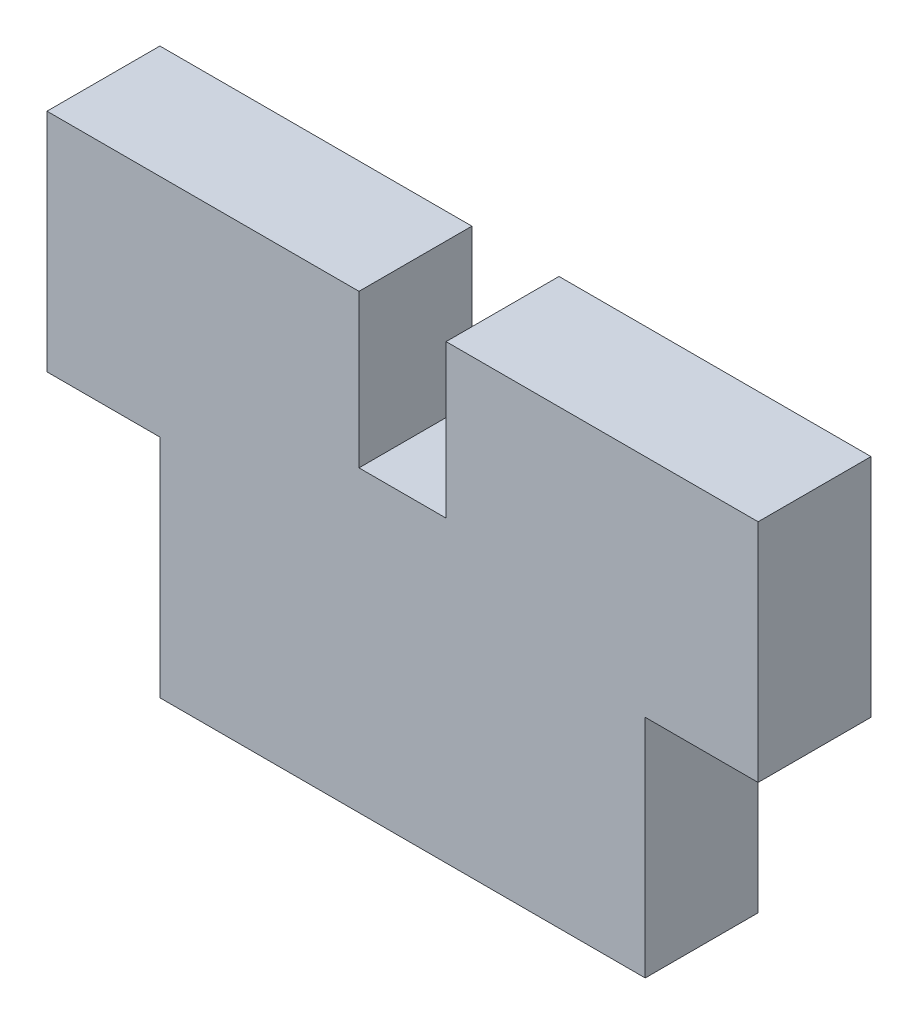
from build123d import *

# Parameters (mm, degrees)
SKETCH2_W           = 40
SKETCH2_H           = 12.7
BOSS_EXTRUDE1_DEPTH = 6.35
SKETCH3_W           = 27.3
SKETCH3_H           = 6.35
BOSS_EXTRUDE2_DEPTH = 12.7
SKETCH4_W           = 4.9
SKETCH4_H           = 6.35
CUT_EXTRUDE1_DEPTH  = 8.6


with BuildPart() as part:
    # Sketch2 → Boss-Extrude1 (new body)
    with BuildSketch(Plane.XY):
        Rectangle(SKETCH2_W, SKETCH2_H)
    extrude(amount=BOSS_EXTRUDE1_DEPTH)

    # Sketch3 → Boss-Extrude2 (add)
    with BuildSketch(Plane.XZ.offset(6.35)):
        with Locations((0, 3.175)):
            Rectangle(SKETCH3_W, SKETCH3_H)
    extrude(amount=BOSS_EXTRUDE2_DEPTH)

    # Sketch4 → Cut-Extrude1 (cut)
    with BuildSketch(Plane(origin=(0, 6.35, 0), x_dir=(1, 0, 0), z_dir=(0, 1, 0))):
        with Locations((0, -3.175)):
            Rectangle(SKETCH4_W, SKETCH4_H)
    extrude(amount=-CUT_EXTRUDE1_DEPTH, mode=Mode.SUBTRACT)


solid = part.part
